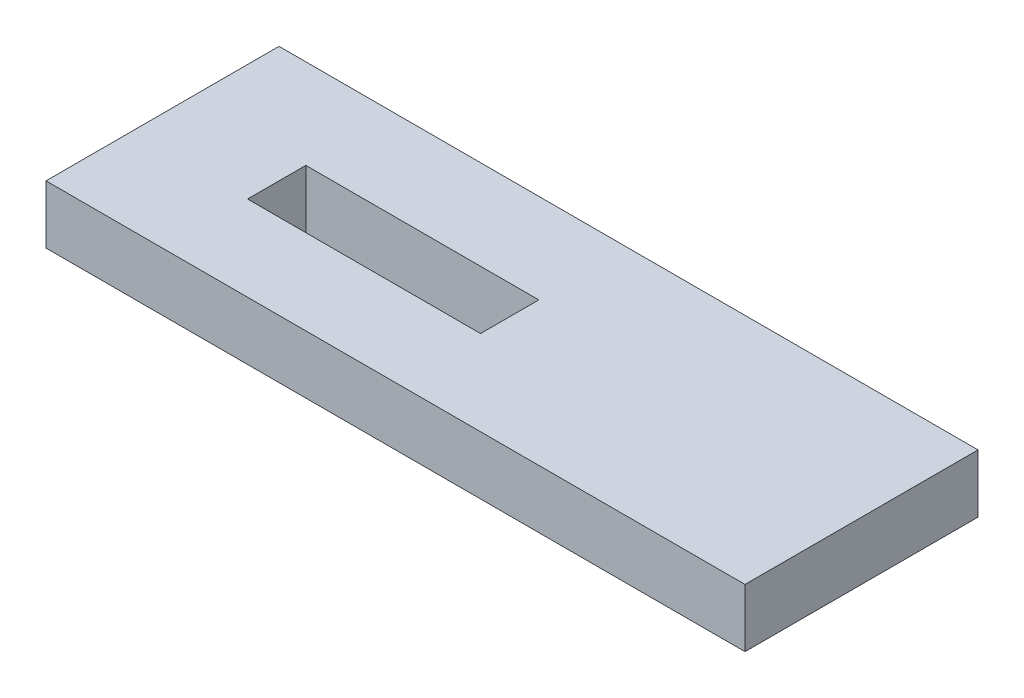
from build123d import *

# Parameters (mm, degrees)
SKETCH1_W           = 76.2
SKETCH1_H           = 25.4
SKETCH1_W_2         = 25.4
SKETCH1_H_2         = 6.35
BOSS_EXTRUDE1_DEPTH = 6.35


with BuildPart() as part:
    # Sketch1 → Boss-Extrude1 (new body)
    with BuildSketch(Plane(origin=(0, 0, 0), x_dir=(1, 0, 0), z_dir=(0, 1, 0))):
        with Locations((38.1, 12.7)):
            Rectangle(SKETCH1_W, SKETCH1_H)
        with Locations((25.4, 12.446)):
            Rectangle(SKETCH1_W_2, SKETCH1_H_2, mode=Mode.SUBTRACT)
    extrude(amount=BOSS_EXTRUDE1_DEPTH)


solid = part.part
